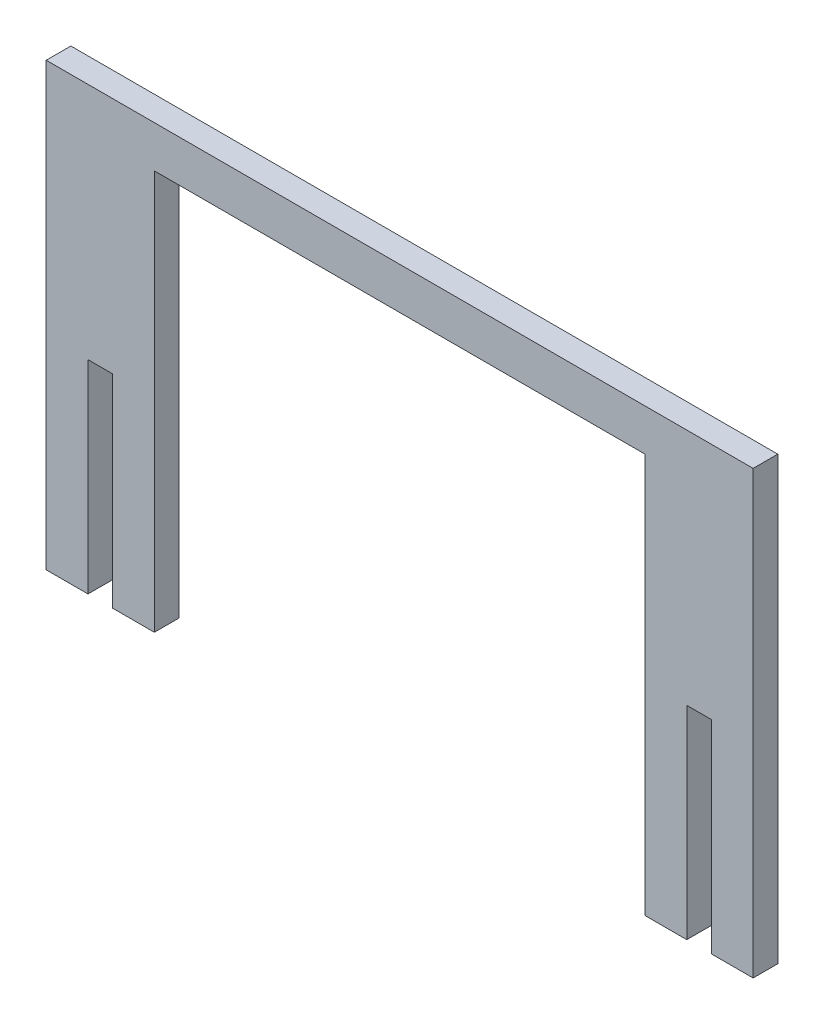
from build123d import *

# Parameters (mm, degrees)
BOSS_EXTRUDE1_DEPTH = 2.9972


with BuildPart() as part:
    # Sketch1 → Boss-Extrude1 (new body)
    with BuildSketch(Plane.XY):
        Polygon((0, 23.9268), (2.9972, 23.9268), (2.9972, -0.762), (8.0772, -0.762), (8.0772, 47.8536), (67.7672, 47.8536), (67.7672, -0.762), (72.8472, -0.762), (72.8472, 23.9268), (75.8444, 23.9268), (75.8444, -0.762), (80.9244, -0.762), (80.9244, 52.9336), (-5.08, 52.9336), (-5.08, -0.762), (0, -0.762), align=None)
    extrude(amount=BOSS_EXTRUDE1_DEPTH)


solid = part.part
